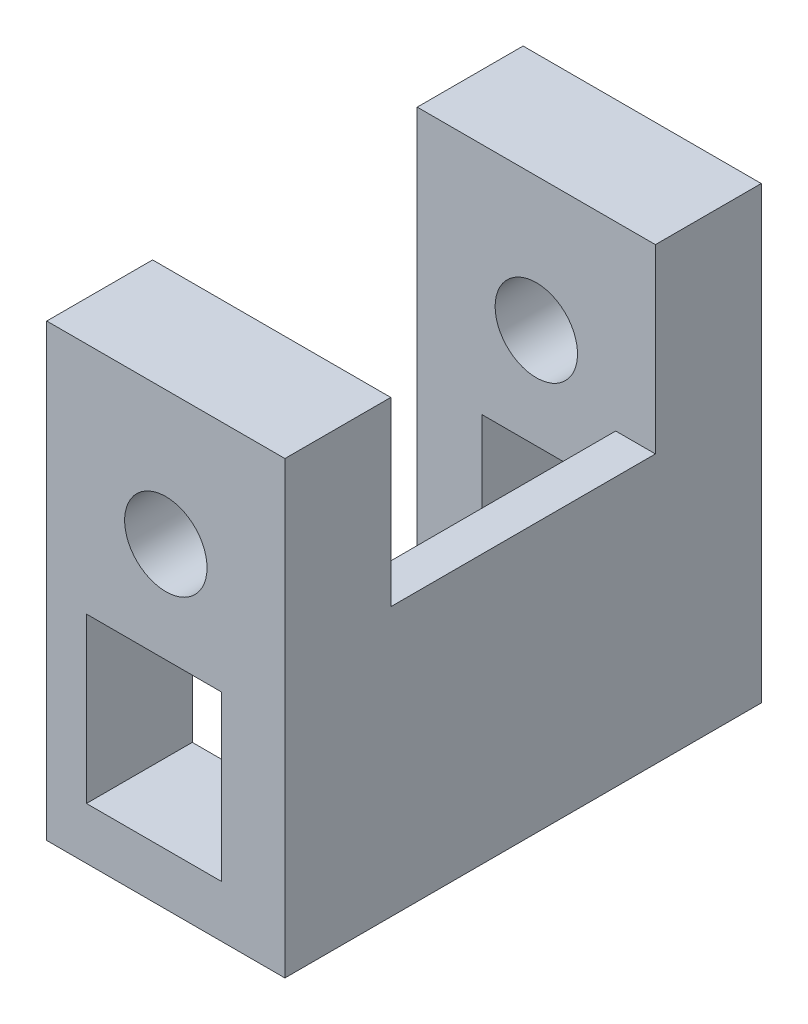
from build123d import *

# Parameters (mm, degrees)
SKIZZE3_W                       = 9
SKIZZE3_H                       = 10.1502367
SKIZZE3_W_2                     = 3.2
SKIZZE3_H_2                     = 6.2
AUFSATZ_LINEAR_AUSTRAGEN2_DEPTH = 4
AUFSATZ_LINEAR_AUSTRAGEN3_DEPTH = 10
SKIZZE6_W                       = 9
SKIZZE6_H                       = 6.8497633
AUFSATZ_LINEAR_AUSTRAGEN5_DEPTH = 4
SKIZZE7_R                       = 1.55688018
SCHNITT_LINEAR_AUSTRAGEN1_DEPTH = 4
SKIZZE8_W                       = 9
SKIZZE8_H                       = 17
SKIZZE8_R                       = 1.55688018
SKIZZE8_W_2                     = 5.098922271
SKIZZE8_H_2                     = 6.2
AUFSATZ_LINEAR_AUSTRAGEN6_DEPTH = 4


with BuildPart() as part:
    # Skizze3 → Aufsatz-Linear austragen2 (new body)
    with BuildSketch(Plane(origin=(0, 0, -22.061362238), x_dir=(-1, 0, 0), z_dir=(0, 0, -1))):
        with Locations((-9.606096766, -3.650507166)):
            Rectangle(SKIZZE3_W, SKIZZE3_H)
        with Locations((-9.155557902, -3.664383383)):
            Rectangle(SKIZZE3_W_2, SKIZZE3_H_2, mode=Mode.SUBTRACT)
    extrude(amount=AUFSATZ_LINEAR_AUSTRAGEN2_DEPTH)

    # Skizze4 → Aufsatz-Linear austragen3 (add)
    with BuildSketch(Plane.XY.offset(-22.061362238)):
        Polygon((12.605305007, 1.424611184), (14.106096766, 1.424611184), (14.106096766, -8.725625516), (12.606096766, -8.725625516), align=None)
    extrude(amount=AUFSATZ_LINEAR_AUSTRAGEN3_DEPTH)

    # Skizze6 → Aufsatz-Linear austragen5 (add)
    with BuildSketch(Plane(origin=(0, 0, -22.061362238), x_dir=(-1, 0, 0), z_dir=(0, 0, -1))):
        with Locations((-9.606096766, 4.849492834)):
            Rectangle(SKIZZE6_W, SKIZZE6_H)
    extrude(amount=AUFSATZ_LINEAR_AUSTRAGEN5_DEPTH)

    # Skizze7 → Schnitt-Linear austragen1 (cut)
    with BuildSketch(Plane(origin=(0, 0, -26.061362238), x_dir=(-1, 0, 0), z_dir=(0, 0, -1))):
        with Locations((-9.606096766, 3.224137783)):
            Circle(SKIZZE7_R)
    extrude(amount=-SCHNITT_LINEAR_AUSTRAGEN1_DEPTH, mode=Mode.SUBTRACT)

    # Skizze8 → Aufsatz-Linear austragen6 (add)
    with BuildSketch(Plane.XY.offset(-12.061362238)):
        with Locations((9.606096766, -0.225625516)):
            Rectangle(SKIZZE8_W, SKIZZE8_H)
        with Locations((9.606096766, 3.224137783)):
            Circle(SKIZZE8_R, mode=Mode.SUBTRACT)
        with Locations((9.155557901, -3.664383383)):
            Rectangle(SKIZZE8_W_2, SKIZZE8_H_2, mode=Mode.SUBTRACT)
    extrude(amount=AUFSATZ_LINEAR_AUSTRAGEN6_DEPTH)


solid = part.part
